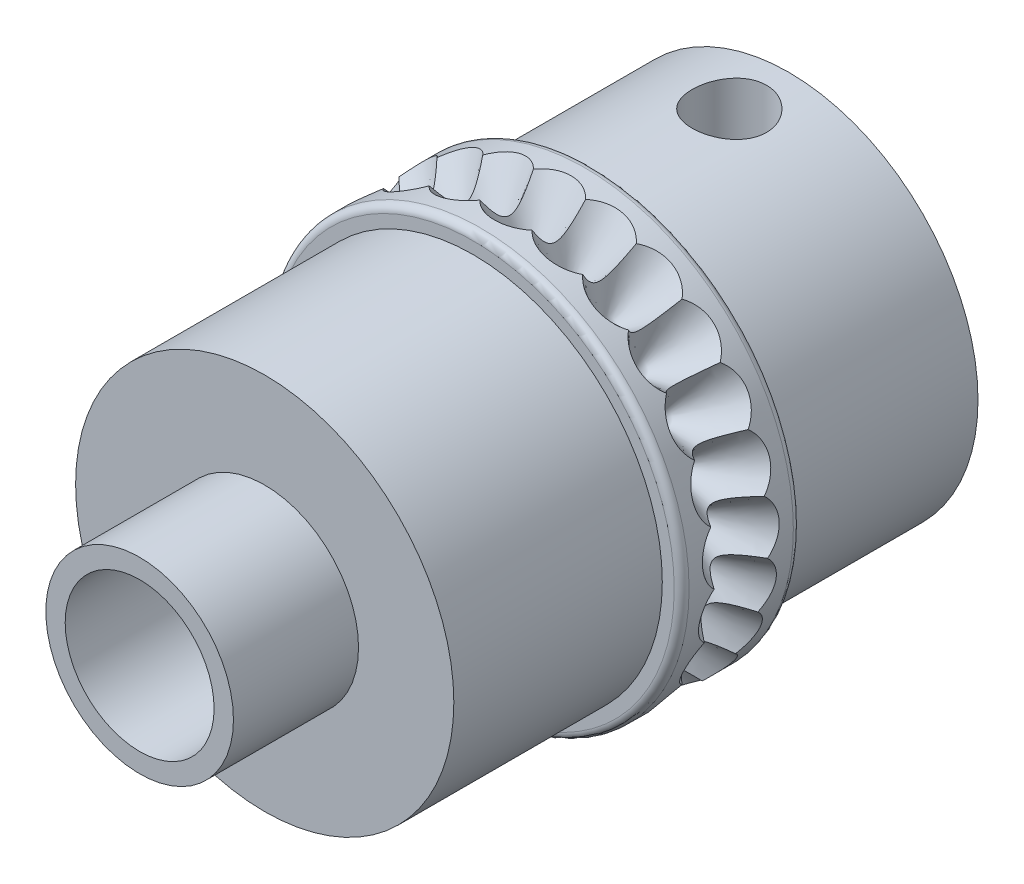
from build123d import *

# Parameters (mm, degrees)
SKETCH1_R           = 7.5
SKETCH1_R_2         = 2.5
BOSS_EXTRUDE1_DEPTH = 2
SKETCH3_R           = 6.35
SKETCH3_R_2         = 2.5
BOSS_EXTRUDE2_DEPTH = 7.1
SKETCH7_W           = 1.25
SKETCH7_H           = 7.5
CIRPATTERN5_COUNT   = 25
SKETCH9_R           = 9.59560007
SKETCH9_R_2         = 7
CUT_EXTRUDE1_DEPTH  = 12.1000001
SKETCH10_R          = 6.35
SKETCH10_R_2        = 3.25
CUT_EXTRUDE2_DEPTH  = 0.5
SKETCH11_R          = 3.15
SKETCH11_R_2        = 2.5
BOSS_EXTRUDE3_DEPTH = 11.2
SKETCH12_R          = 6.35
SKETCH12_R_2        = 3.15
BOSS_EXTRUDE4_DEPTH = 7
FILLET1_R           = 0.25


with BuildPart() as part:
    # Sketch1 → Boss-Extrude1 (new body, symmetric)
    with BuildSketch(Plane.XY):
        Circle(SKETCH1_R)
        Circle(SKETCH1_R_2, mode=Mode.SUBTRACT)
    extrude(amount=BOSS_EXTRUDE1_DEPTH, both=True)

    # Sketch2 → Cut-Revolve2 (revolve, cut)
    with BuildSketch(Plane(origin=(0, 0, 0), x_dir=(0, 0, -1), z_dir=(1, 0, 0))):
        Polygon((0, 4.77), (1.78737673, 7.865827309), (0, 7.865827309), align=None)
    cut_revolve2 = revolve(axis=Axis((0, 0.194971792, 0), (0, 1, 0)), mode=Mode.SUBTRACT)

    # Sketch3 → Boss-Extrude2 (add)
    with BuildSketch(Plane(origin=(0, 0, -2), x_dir=(-1, 0, 0), z_dir=(0, 0, -1))):
        Circle(SKETCH3_R)
        Circle(SKETCH3_R_2, mode=Mode.SUBTRACT)
    extrude(amount=BOSS_EXTRUDE2_DEPTH)

    # Sketch7 → M3 Tapped Hole1 (revolve, cut)
    with BuildSketch(Plane(origin=(0, 0, -6.6), x_dir=(0, 0, -1), z_dir=(1, 0, 0))):
        with Locations((0.625, 3.75)):
            Rectangle(SKETCH7_W, SKETCH7_H)
    revolve(axis=Axis((0, -6.35, -6.6), (0, 1, 0)), mode=Mode.SUBTRACT)

    # CirPattern5: Cut-Revolve2 ×25 about axis
    cirpattern5_axis = Axis((0, 0, -9.1), (0, 0, 1))
    for i in range(1, CIRPATTERN5_COUNT):
        add(cut_revolve2.rotate(cirpattern5_axis, i * 360 / CIRPATTERN5_COUNT), mode=Mode.SUBTRACT)

    # Sketch9 → Cut-Extrude1 (cut, through all)
    with BuildSketch(Plane.XY.offset(2)):
        Circle(SKETCH9_R)
        Circle(SKETCH9_R_2, mode=Mode.SUBTRACT)
    extrude(amount=-CUT_EXTRUDE1_DEPTH, mode=Mode.SUBTRACT)

    # Sketch10 → Cut-Extrude2 (cut)
    with BuildSketch(Plane(origin=(0, 0, -9.1), x_dir=(-1, 0, 0), z_dir=(0, 0, -1))):
        Circle(SKETCH10_R)
        Circle(SKETCH10_R_2, mode=Mode.SUBTRACT)
    extrude(amount=-CUT_EXTRUDE2_DEPTH, mode=Mode.SUBTRACT)

    # Sketch11 → Boss-Extrude3 (add)
    with BuildSketch(Plane.XY.offset(2)):
        Circle(SKETCH11_R)
        Circle(SKETCH11_R_2, mode=Mode.SUBTRACT)
    extrude(amount=BOSS_EXTRUDE3_DEPTH)

    # Sketch12 → Boss-Extrude4 (add)
    with BuildSketch(Plane.XY.offset(2)):
        Circle(SKETCH12_R)
        Circle(SKETCH12_R_2, mode=Mode.SUBTRACT)
    extrude(amount=BOSS_EXTRUDE4_DEPTH)

    # Fillet1
    fillet1_edges = [part.edges().sort_by_distance(p)[0] for p in [
        (-7, 0, 2),
        (-7, 0, -2),
    ]]
    fillet(fillet1_edges, radius=FILLET1_R)


solid = part.part
